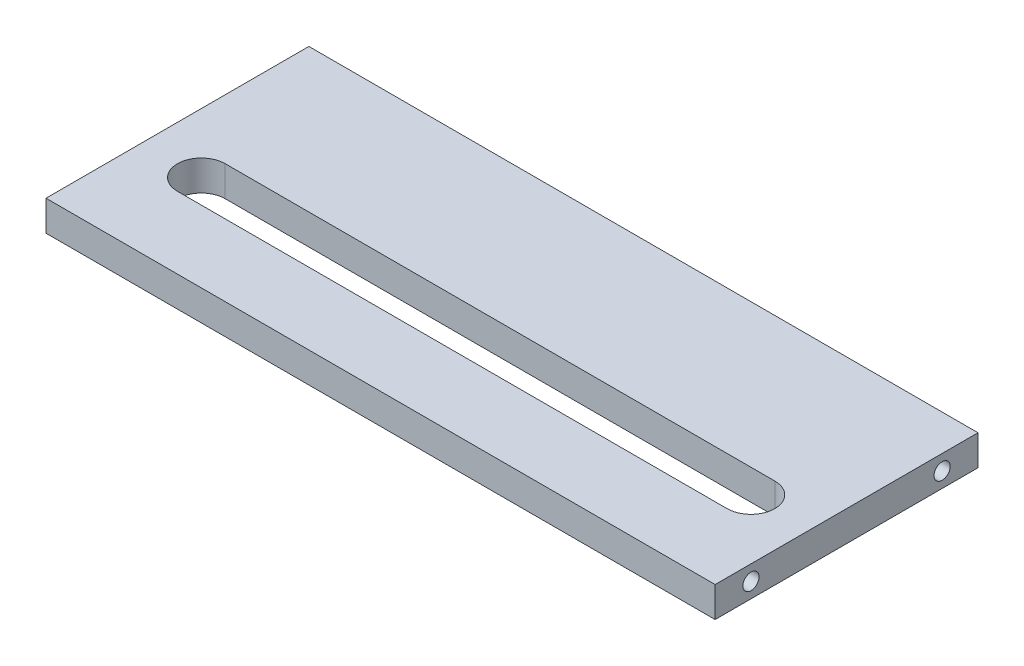
from build123d import *

# Parameters (mm, degrees)
CROQUIS1_W              = 280
CROQUIS1_H              = 110
SALIENTE_EXTRUIR1_DEPTH = 12.7
CORTAR_EXTRUIR2_DEPTH   = 20
CROQUIS5_R              = 3.375
CORTAR_EXTRUIR5_DEPTH   = 30
CROQUIS6_R              = 3.375
CORTAR_EXTRUIR6_DEPTH   = 30


with BuildPart() as part:
    # Croquis1 → Saliente-Extruir1 (new body)
    with BuildSketch(Plane(origin=(0, 0, 0), x_dir=(1, 0, 0), z_dir=(0, 1, 0))):
        with Locations((14.294294294, 1.756756757)):
            Rectangle(CROQUIS1_W, CROQUIS1_H)
    extrude(amount=SALIENTE_EXTRUIR1_DEPTH)

    # Croquis2 → Cortar-Extruir2 (cut)
    with BuildSketch(Plane(origin=(0, 0, 0), x_dir=(1, 0, 0), z_dir=(0, 1, 0))):
        with BuildLine():
            Line((-100.705705706, -3.243243243), (129.294294294, -3.243243243))
            ThreePointArc((129.294294294, -3.243243243), (139.294294294, -13.243243243), (129.294294294, -23.243243243))
            Line((129.294294294, -23.243243243), (-100.705705706, -23.243243243))
            ThreePointArc((-100.705705706, -23.243243243), (-110.705705706, -13.243243243), (-100.705705706, -3.243243243))
        make_face()
    extrude(amount=CORTAR_EXTRUIR2_DEPTH, mode=Mode.SUBTRACT)

    # Croquis5 → Cortar-Extruir5 (cut)
    with BuildSketch(Plane.ZY.offset(125.705705706)):
        with Locations((38.243243243, 6.35)):
            Circle(CROQUIS5_R)
        with Locations((-41.756756757, 6.35)):
            Circle(CROQUIS5_R)
    extrude(amount=-CORTAR_EXTRUIR5_DEPTH, mode=Mode.SUBTRACT)

    # Croquis6 → Cortar-Extruir6 (cut)
    with BuildSketch(Plane(origin=(154.294294294, 0, 0), x_dir=(0, 0, -1), z_dir=(1, 0, 0))):
        with Locations((41.756756757, 6.35)):
            Circle(CROQUIS6_R)
        with Locations((-38.243243243, 6.35)):
            Circle(CROQUIS6_R)
    extrude(amount=-CORTAR_EXTRUIR6_DEPTH, mode=Mode.SUBTRACT)


solid = part.part
